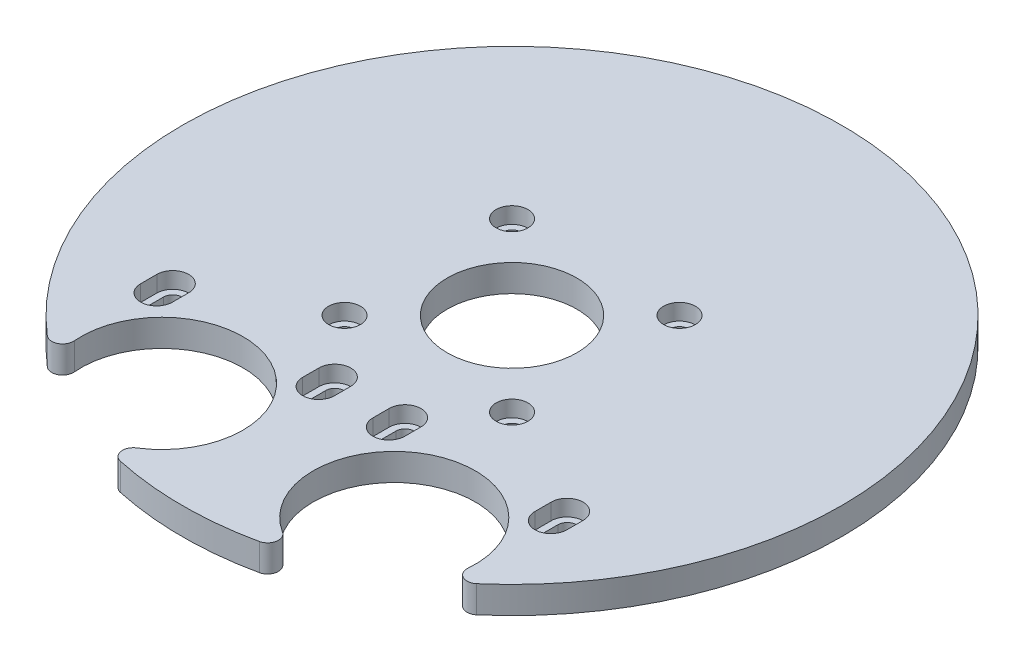
from build123d import *

# Parameters (mm, degrees)
CROQUIS1_R              = 12
SALIENTE_EXTRUIR1_DEPTH = 5
CROQUIS2_R              = 1.7
CORTAR_EXTRUIR1_DEPTH   = 5
CROQUIS3_R              = 2.95
CORTAR_EXTRUIR2_DEPTH   = 3


with BuildPart() as part:
    # Croquis1 → Saliente-Extruir1 (new body)
    with BuildSketch(Plane(origin=(0, 0, 0), x_dir=(1, 0, 0), z_dir=(0, 1, 0))):
        with BuildLine():
            ThreePointArc((-12.848290026, -59.631547384), (0, -61), (12.848290026, -59.631547384))
            ThreePointArc((12.848290026, -59.631547384), (14.396355702, -58.025376654), (13.494442308, -55.985071779))
            ThreePointArc((13.494442308, -55.985071779), (14.829055081, -29.865027209), (36.444464672, -44.589564139))
            ThreePointArc((36.444464672, -44.589564139), (37.524744291, -46.541303798), (39.740011147, -46.278845211))
            ThreePointArc((39.740011147, -46.278845211), (0, 61), (-39.740011147, -46.278845211))
            ThreePointArc((-39.740011147, -46.278845211), (-37.524744291, -46.541303798), (-36.444464672, -44.589564139))
            ThreePointArc((-36.444464672, -44.589564139), (-14.829055081, -29.865027209), (-13.494442308, -55.985071779))
            ThreePointArc((-13.494442308, -55.985071779), (-14.396355702, -58.025376654), (-12.848290026, -59.631547384))
        make_face()
        Circle(CROQUIS1_R, mode=Mode.SUBTRACT)
    extrude(amount=SALIENTE_EXTRUIR1_DEPTH)

    # Croquis2 → Cortar-Extruir1 (cut)
    with BuildSketch(Plane(origin=(0, 5, 0), x_dir=(1, 0, 0), z_dir=(0, 1, 0))):
        with Locations((-15.5, 15.5)):
            Circle(CROQUIS2_R)
        with Locations((-15.5, -15.5)):
            Circle(CROQUIS2_R)
        with Locations((15.5, -15.5)):
            Circle(CROQUIS2_R)
        with Locations((15.5, 15.5)):
            Circle(CROQUIS2_R)
        with BuildLine():
            Line((-34.8, -26.3), (-34.8, -29.3))
            ThreePointArc((-34.8, -29.3), (-36.5, -31), (-38.2, -29.3))
            Line((-38.2, -29.3), (-38.2, -26.3))
            ThreePointArc((-38.2, -26.3), (-36.5, -24.6), (-34.8, -26.3))
        make_face()
        with BuildLine():
            Line((-4.8, -26.3), (-4.8, -29.3))
            ThreePointArc((-4.8, -29.3), (-6.5, -31), (-8.2, -29.3))
            Line((-8.2, -29.3), (-8.2, -26.3))
            ThreePointArc((-8.2, -26.3), (-6.5, -24.6), (-4.8, -26.3))
        make_face()
        with BuildLine():
            Line((4.8, -26.3), (4.8, -29.3))
            ThreePointArc((4.8, -29.3), (6.5, -31), (8.2, -29.3))
            Line((8.2, -29.3), (8.2, -26.3))
            ThreePointArc((8.2, -26.3), (6.5, -24.6), (4.8, -26.3))
        make_face()
        with BuildLine():
            Line((34.8, -26.3), (34.8, -29.3))
            ThreePointArc((34.8, -29.3), (36.5, -31), (38.2, -29.3))
            Line((38.2, -29.3), (38.2, -26.3))
            ThreePointArc((38.2, -26.3), (36.5, -24.6), (34.8, -26.3))
        make_face()
    extrude(amount=-CORTAR_EXTRUIR1_DEPTH, mode=Mode.SUBTRACT)

    # Croquis3 → Cortar-Extruir2 (cut)
    with BuildSketch(Plane(origin=(0, 5, 0), x_dir=(1, 0, 0), z_dir=(0, 1, 0))):
        with Locations((-15.5, 15.5)):
            Circle(CROQUIS3_R)
        with Locations((15.5, 15.5)):
            Circle(CROQUIS3_R)
        with Locations((15.5, -15.5)):
            Circle(CROQUIS3_R)
        with Locations((-15.5, -15.5)):
            Circle(CROQUIS3_R)
        with BuildLine():
            Line((-33.55, -26.3), (-33.55, -29.3))
            ThreePointArc((-33.55, -29.3), (-36.5, -32.25), (-39.45, -29.3))
            Line((-39.45, -29.3), (-39.45, -26.3))
            ThreePointArc((-39.45, -26.3), (-36.5, -23.35), (-33.55, -26.3))
        make_face()
        with BuildLine():
            Line((-3.55, -26.3), (-3.55, -29.3))
            ThreePointArc((-3.55, -29.3), (-6.5, -32.25), (-9.45, -29.3))
            Line((-9.45, -29.3), (-9.45, -26.3))
            ThreePointArc((-9.45, -26.3), (-6.5, -23.35), (-3.55, -26.3))
        make_face()
        with BuildLine():
            Line((9.45, -26.3), (9.45, -29.3))
            ThreePointArc((9.45, -29.3), (6.5, -32.25), (3.55, -29.3))
            Line((3.55, -29.3), (3.55, -26.3))
            ThreePointArc((3.55, -26.3), (6.5, -23.35), (9.45, -26.3))
        make_face()
        with BuildLine():
            Line((39.45, -26.3), (39.45, -29.3))
            ThreePointArc((39.45, -29.3), (36.5, -32.25), (33.55, -29.3))
            Line((33.55, -29.3), (33.55, -26.3))
            ThreePointArc((33.55, -26.3), (36.5, -23.35), (39.45, -26.3))
        make_face()
    extrude(amount=-CORTAR_EXTRUIR2_DEPTH, mode=Mode.SUBTRACT)


solid = part.part
